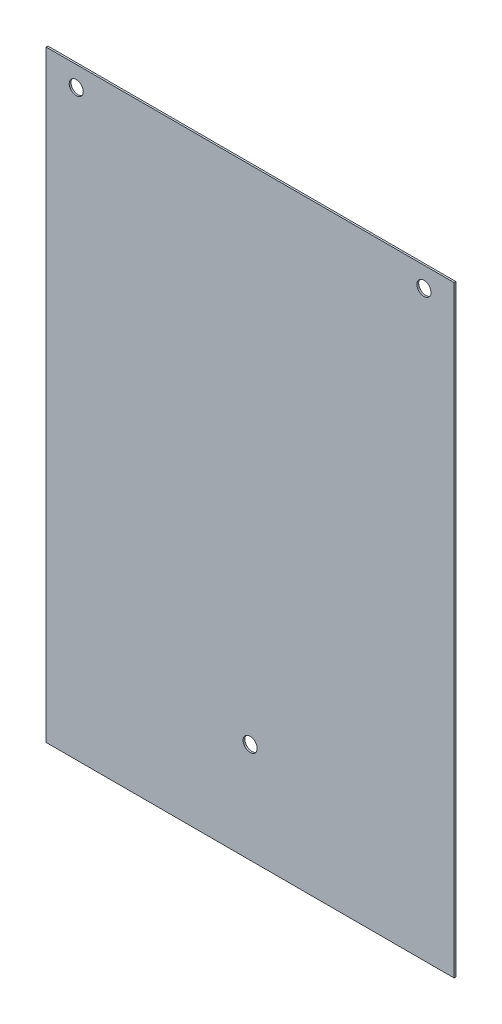
from build123d import *

# Parameters (mm, degrees)
SKETCH_1_W         = 203.2
SKETCH_1_H         = 300
EXTRUDE_1_DEPTH    = 0.9
SKETCH_2_R         = 3.5
CUT_EXTRUDE1_DEPTH = 0.9


with BuildPart() as part:
    # 草图1 → 凸台-拉伸1 (new body)
    with BuildSketch(Plane.XY):
        Rectangle(SKETCH_1_W, SKETCH_1_H)
    extrude(amount=EXTRUDE_1_DEPTH)

    # 草图2 → Cut-Extrude1 (cut)
    with BuildSketch(Plane.XY.offset(0.9)):
        with Locations((-86.6, 140)):
            Circle(SKETCH_2_R)
        with Locations((86.6, 140)):
            Circle(SKETCH_2_R)
        with Locations((0, -100)):
            Circle(SKETCH_2_R)
    extrude(amount=-CUT_EXTRUDE1_DEPTH, mode=Mode.SUBTRACT)


solid = part.part
